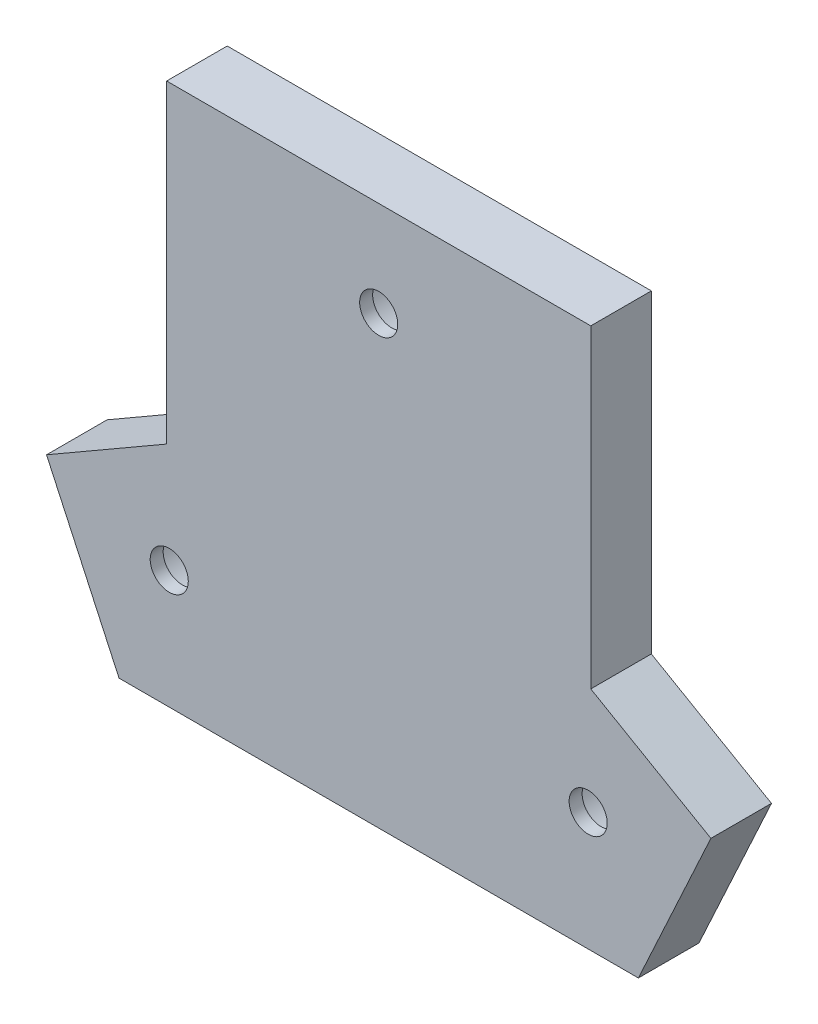
from build123d import *

# Parameters (mm, degrees)
SKETCH1_R           = 5.1
SKETCH1_R_2         = 2.2
BOSS_EXTRUDE1_DEPTH = 7
SKETCH1_3_R         = 5.1
SKETCH1_3_R_2       = 2.2
CUT_EXTRUDE1_DEPTH  = 5.5
SKETCH1_4_R         = 2.2
CUT_EXTRUDE2_DEPTH  = 7


with BuildPart() as part:
    # Sketch1 → Boss-Extrude1 (new body)
    with BuildSketch(Plane.XY):
        Polygon((54.5, 26.172980381), (54.5, 62.5), (5.5, 62.5), (5.5, 26.172980381), (-8.376844495, 18.161180477), (0, 0), (60, 0), (68.376844495, 18.161180477), align=None)
        with Locations((29.999295859, 51.499999991)):
            Circle(SKETCH1_R, mode=Mode.SUBTRACT)
        with Locations((5.800227015, 13.687854711)):
            Circle(SKETCH1_R, mode=Mode.SUBTRACT)
        with Locations((54.200362799, 13.689133529)):
            Circle(SKETCH1_R, mode=Mode.SUBTRACT)
        with Locations((5.800227015, 13.687854711)):
            Circle(SKETCH1_R)
        with Locations((5.800227015, 13.687854711)):
            Circle(SKETCH1_R_2, mode=Mode.SUBTRACT)
        with Locations((5.800227015, 13.687854711)):
            Circle(SKETCH1_R_2)
        with Locations((54.200362799, 13.689133529)):
            Circle(SKETCH1_R)
        with Locations((54.200362799, 13.689133529)):
            Circle(SKETCH1_R_2, mode=Mode.SUBTRACT)
        with Locations((54.200362799, 13.689133529)):
            Circle(SKETCH1_R_2)
        with Locations((29.999295859, 51.499999991)):
            Circle(SKETCH1_R)
        with Locations((29.999295859, 51.499999991)):
            Circle(SKETCH1_R_2, mode=Mode.SUBTRACT)
        with Locations((29.999295859, 51.499999991)):
            Circle(SKETCH1_R_2)
    extrude(amount=BOSS_EXTRUDE1_DEPTH)

    # Sketch1_3 → Cut-Extrude1 (cut)
    with BuildSketch(Plane.XY):
        with Locations((29.999295859, 51.499999991)):
            Circle(SKETCH1_3_R)
        with Locations((29.999295859, 51.499999991)):
            Circle(SKETCH1_3_R_2, mode=Mode.SUBTRACT)
        with Locations((54.200362799, 13.689133529)):
            Circle(SKETCH1_3_R)
        with Locations((54.200362799, 13.689133529)):
            Circle(SKETCH1_3_R_2, mode=Mode.SUBTRACT)
        with Locations((5.800227015, 13.687854711)):
            Circle(SKETCH1_3_R)
        with Locations((5.800227015, 13.687854711)):
            Circle(SKETCH1_3_R_2, mode=Mode.SUBTRACT)
    extrude(amount=CUT_EXTRUDE1_DEPTH, mode=Mode.SUBTRACT)

    # Sketch1_4 → Cut-Extrude2 (cut)
    with BuildSketch(Plane.XY):
        with Locations((54.200362799, 13.689133529)):
            Circle(SKETCH1_4_R)
        with Locations((5.800227015, 13.687854711)):
            Circle(SKETCH1_4_R)
        with Locations((29.999295859, 51.499999991)):
            Circle(SKETCH1_4_R)
    extrude(amount=CUT_EXTRUDE2_DEPTH, mode=Mode.SUBTRACT)


solid = part.part
